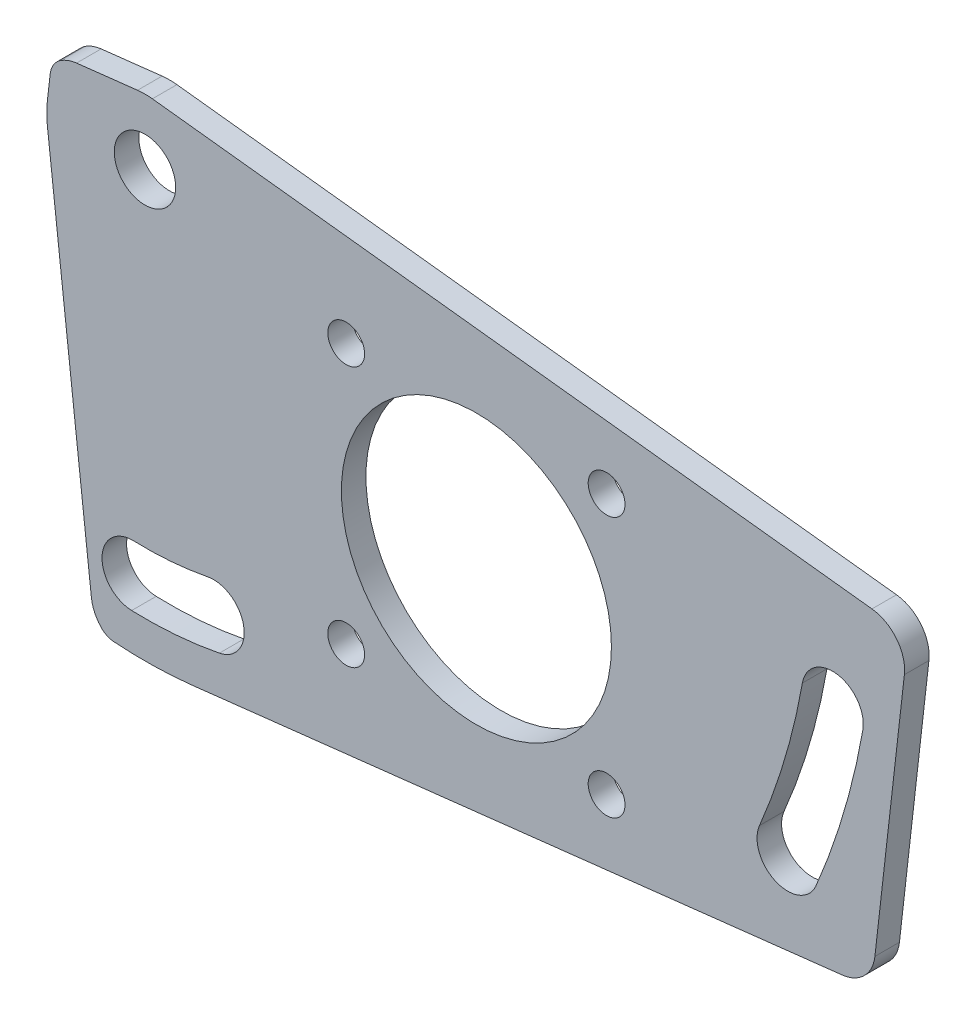
from build123d import *

# Parameters (mm, degrees)
SZKIC1_R                    = 11
SZKIC1_R_2                  = 2.5
DODANIE_WYCI_GNI_CIE1_DEPTH = 2
SZKIC2_R                    = 1.5
WYTNIJ_WYCI_GNI_CIE2_DEPTH  = 3
SZKIC3_OUTSIDE_W            = 88.13
SZKIC3_OUTSIDE_H            = 58.13
WYTNIJ_WYCI_GNI_CIE3_DEPTH  = 3


with BuildPart() as part:
    # Szkic1 → Dodanie-wyciągnięcie1 (new body)
    with BuildSketch(Plane.XY):
        with BuildLine():
            Line((-32, -20), (32, -20))
            ThreePointArc((32, -20), (34.121320344, -19.121320344), (35, -17))
            Line((35, -17), (35, 17))
            ThreePointArc((35, 17), (34.121320344, 19.121320344), (32, 20))
            Line((32, 20), (-32, 20))
            ThreePointArc((-32, 20), (-34.121320344, 19.121320344), (-35, 17))
            Line((-35, 17), (-35, -17))
            ThreePointArc((-35, -17), (-34.121320344, -19.121320344), (-32, -20))
        make_face()
        Circle(SZKIC1_R, mode=Mode.SUBTRACT)
        with Locations((-27, 14.666666667)):
            Circle(SZKIC1_R_2, mode=Mode.SUBTRACT)
        with BuildLine():
            ThreePointArc((27.662313373, -8.536108756), (29.93756488, -2.199008421), (31.480810618, 4.354921901))
            ThreePointArc((31.480810618, 4.354921901), (29.452911679, 7.251061728), (26.556771853, 5.223162789))
            ThreePointArc((26.556771853, 5.223162789), (25.143466206, -0.778931698), (23.059789106, -6.582453114))
            ThreePointArc((23.059789106, -6.582453114), (24.384223418, -9.860543068), (27.662313373, -8.536108756))
        make_face(mode=Mode.SUBTRACT)
        with BuildLine():
            ThreePointArc((-28.085714286, -16.981382282), (-24.496074307, -16.900850402), (-20.93862552, -16.414477411))
            ThreePointArc((-20.93862552, -16.414477411), (-18.963380552, -13.482173315), (-21.895684648, -11.506928346))
            ThreePointArc((-21.895684648, -11.506928346), (-24.891430995, -11.916505602), (-27.914285714, -11.984321922))
            ThreePointArc((-27.914285714, -11.984321922), (-30.49853018, -14.397137816), (-28.085714286, -16.981382282))
        make_face(mode=Mode.SUBTRACT)
    extrude(amount=DODANIE_WYCI_GNI_CIE1_DEPTH)

    # Szkic2 → Wytnij-wyciągnięcie2 (cut, through all)
    with BuildSketch(Plane.XY):
        with Locations((-10.606601718, 10.606601718)):
            Circle(SZKIC2_R)
        with Locations((10.606601718, 10.606601718)):
            Circle(SZKIC2_R)
        with Locations((10.606601718, -10.606601718)):
            Circle(SZKIC2_R)
        with Locations((-10.606601718, -10.606601718)):
            Circle(SZKIC2_R)
    extrude(amount=WYTNIJ_WYCI_GNI_CIE2_DEPTH, mode=Mode.SUBTRACT)

    # Szkic3 outside → Wytnij-wyciągnięcie3 (cut, through all)
    with BuildSketch(Plane.XY):
        Rectangle(SZKIC3_OUTSIDE_W, SZKIC3_OUTSIDE_H)
        with BuildLine():
            Line((32.464358731, -11.108986267), (34.865595884, 9.966401743))
            ThreePointArc((34.865595884, 9.966401743), (34.232704788, 12.173555294), (32.224489958, 13.286726951))
            Line((32.224489958, 13.286726951), (-26.396249527, 19.965716564))
            ThreePointArc((-26.396249527, 19.965716564), (-27, 20), (-27.603750473, 19.965716564))
            Line((-27.603750473, 19.965716564), (-32.571609752, 19.399700495))
            ThreePointArc((-32.571609752, 19.399700495), (-33.247974324, 19.241713465), (-33.869879413, 18.932419111))
            ThreePointArc((-33.869879413, 18.932419111), (-34.450895793, 18.337181113), (-34.723108417, 17.551185823))
            Line((-34.723108417, 17.551185823), (-34.948574845, 15.572292377))
            ThreePointArc((-34.948574845, 15.572292377), (-35, 14.666666667), (-34.948574845, 13.761040957))
            Line((-34.948574845, 13.761040957), (-31.363806409, -17.702067807))
            ThreePointArc((-31.363806409, -17.702067807), (-31.101077058, -18.632320729), (-30.556161181, -19.430734091))
            ThreePointArc((-30.556161181, -19.430734091), (-30.098141008, -19.761880936), (-29.551624806, -19.905966855))
            ThreePointArc((-29.551624806, -19.905966855), (-26.310608357, -19.993144599), (-23.075621923, -19.777157663))
            Line((-23.075621923, -19.777157663), (29.823252805, -13.750092193))
            ThreePointArc((29.823252805, -13.750092193), (31.604963507, -12.890696969), (32.464358731, -11.108986267))
        make_face(mode=Mode.SUBTRACT)
    extrude(amount=WYTNIJ_WYCI_GNI_CIE3_DEPTH, mode=Mode.SUBTRACT)


solid = part.part
